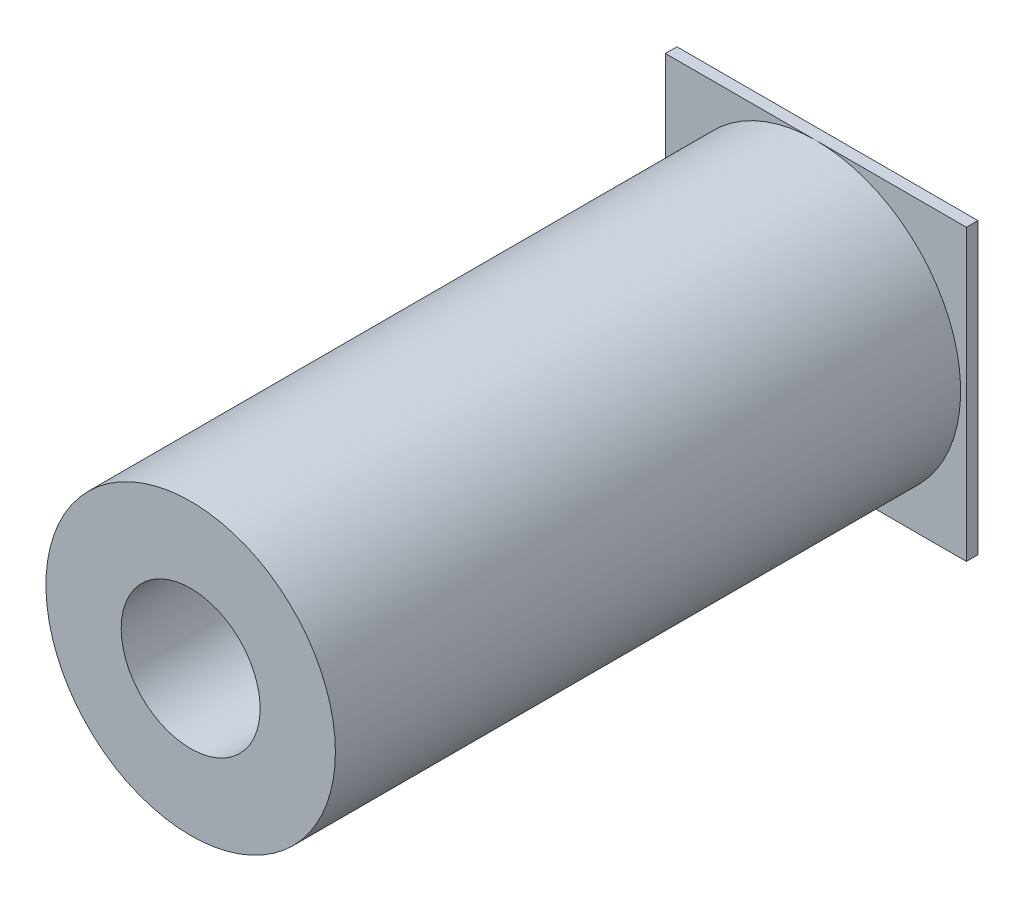
from build123d import *

# Parameters (mm, degrees)
SKETCH1_W           = 26
SKETCH1_H           = 25
BOSS_EXTRUDE1_DEPTH = 1
SKETCH2_R           = 12.5
BOSS_EXTRUDE2_DEPTH = 54
SKETCH3_R           = 6
CUT_EXTRUDE1_DEPTH  = 56


with BuildPart() as part:
    # Sketch1 → Boss-Extrude1 (new body)
    with BuildSketch(Plane.XY):
        Rectangle(SKETCH1_W, SKETCH1_H)
    extrude(amount=BOSS_EXTRUDE1_DEPTH)

    # Sketch2 → Boss-Extrude2 (add)
    with BuildSketch(Plane.XY.offset(1)):
        Circle(SKETCH2_R)
    extrude(amount=BOSS_EXTRUDE2_DEPTH)

    # Sketch3 → Cut-Extrude1 (cut, through all)
    with BuildSketch(Plane(origin=(0, 0, 0), x_dir=(-1, 0, 0), z_dir=(0, 0, -1))):
        Circle(SKETCH3_R)
    extrude(amount=-CUT_EXTRUDE1_DEPTH, mode=Mode.SUBTRACT)


solid = part.part
